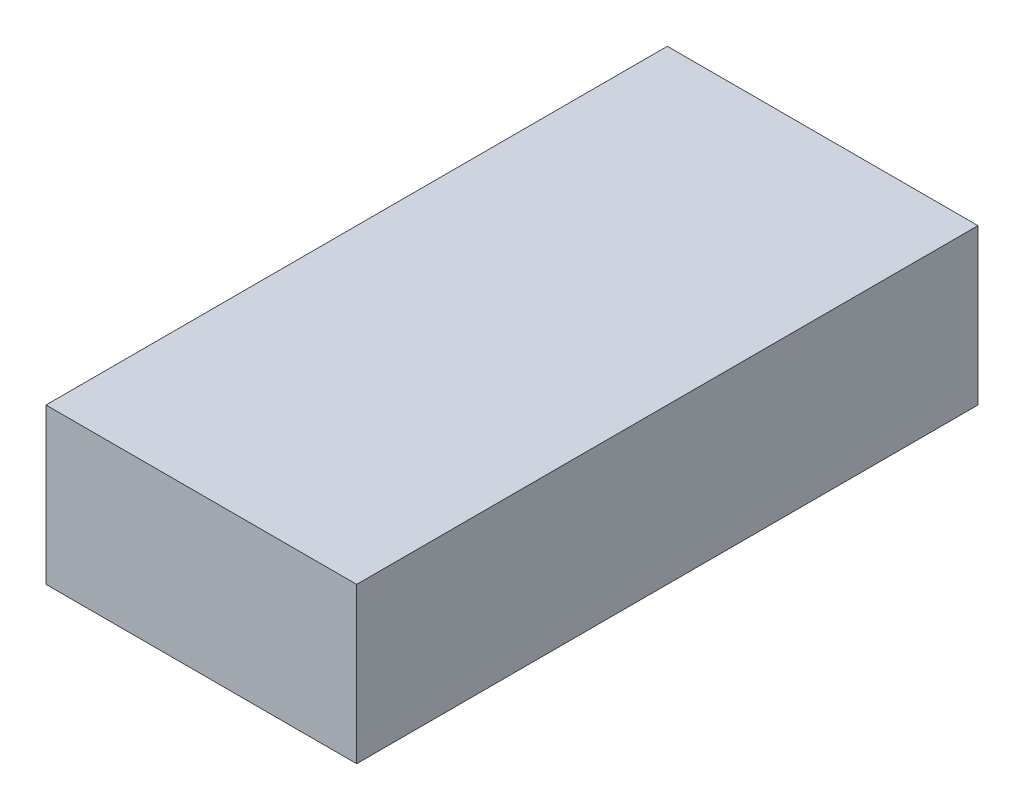
from build123d import *

# Parameters (mm, degrees)
SKETCH1_W           = 50
SKETCH1_H           = 100
BOSS_EXTRUDE1_DEPTH = 25


with BuildPart() as part:
    # Sketch1 → Boss-Extrude1 (new body)
    with BuildSketch(Plane(origin=(0, 0, 0), x_dir=(1, 0, 0), z_dir=(0, 1, 0))):
        with Locations((-25.152027434, 32.669980049)):
            Rectangle(SKETCH1_W, SKETCH1_H)
    extrude(amount=BOSS_EXTRUDE1_DEPTH)


solid = part.part
